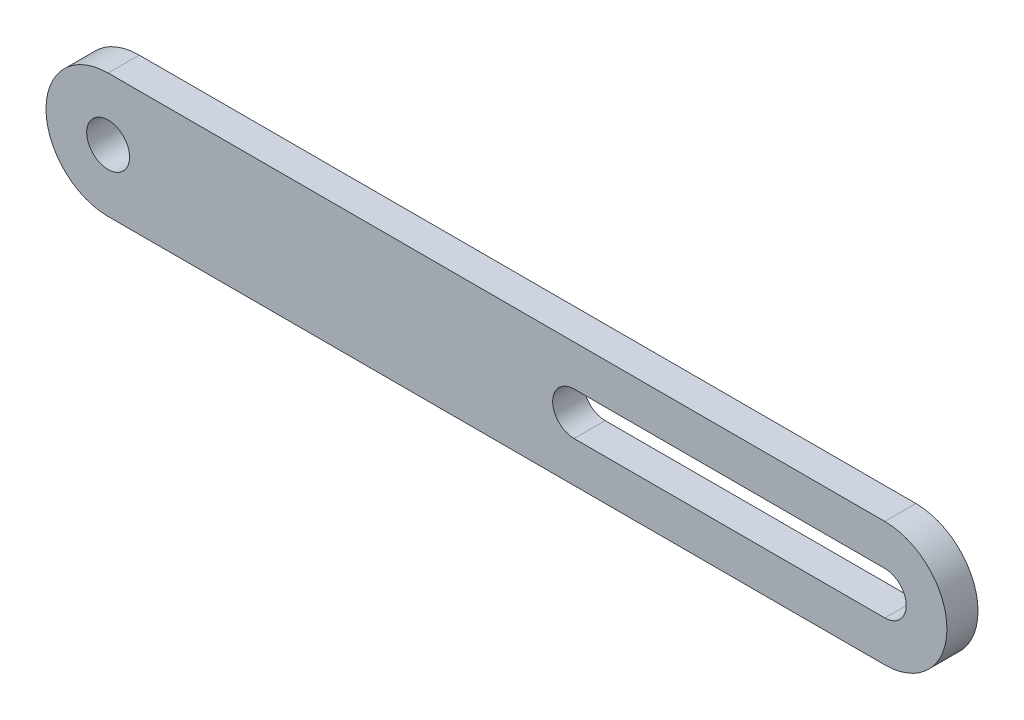
from build123d import *

# Parameters (mm, degrees)
BOSS_EXTRUDE1_DEPTH     = 2.54
CUT_EXTRUDE1_START      = -3.54
SKETCH2_R               = 1.7526
CUT_EXTRUDE1_DEPTH      = 4.54
CUT_EXTRUDE2_DEPTH      = 1
CUT_EXTRUDE2_DEPTH_BACK = 3.54


with BuildPart() as part:
    # Sketch1 → Boss-Extrude1 (new body)
    with BuildSketch(Plane.XY):
        with BuildLine():
            Line((0, 5.08), (63.5, 5.08))
            ThreePointArc((63.5, 5.08), (68.58, 0), (63.5, -5.08))
            Line((63.5, -5.08), (0, -5.08))
            ThreePointArc((0, -5.08), (-5.08, 0), (0, 5.08))
        make_face()
    extrude(amount=BOSS_EXTRUDE1_DEPTH)

    # Sketch2 → Cut-Extrude1 (cut)
    with BuildSketch(Plane.XY.offset(2.54).offset(CUT_EXTRUDE1_START)):
        Circle(SKETCH2_R)
    cut_extrude1 = extrude(amount=CUT_EXTRUDE1_DEPTH, mode=Mode.SUBTRACT)

    # Mirror1: Cut-Extrude1 across plane
    add(cut_extrude1.mirror(Plane(origin=(31.75, 0, 0), x_dir=(0, 0, 1), z_dir=(1, 0, 0))), mode=Mode.SUBTRACT)

    # Sketch4 → Cut-Extrude2 (cut, two sides)
    with BuildSketch(Plane.XY.offset(2.54)) as cut_extrude2_sk:
        with BuildLine():
            Line((63.5, -1.7526), (38.09873006, -1.7526))
            ThreePointArc((38.09873006, -1.7526), (36.34613006, 0), (38.09873006, 1.7526))
            Line((38.09873006, 1.7526), (63.5, 1.7526))
            ThreePointArc((63.5, 1.7526), (65.2526, 0), (63.5, -1.7526))
        make_face()
    extrude(amount=CUT_EXTRUDE2_DEPTH, mode=Mode.SUBTRACT)
    extrude(cut_extrude2_sk.sketch, amount=-CUT_EXTRUDE2_DEPTH_BACK, mode=Mode.SUBTRACT)


solid = part.part
